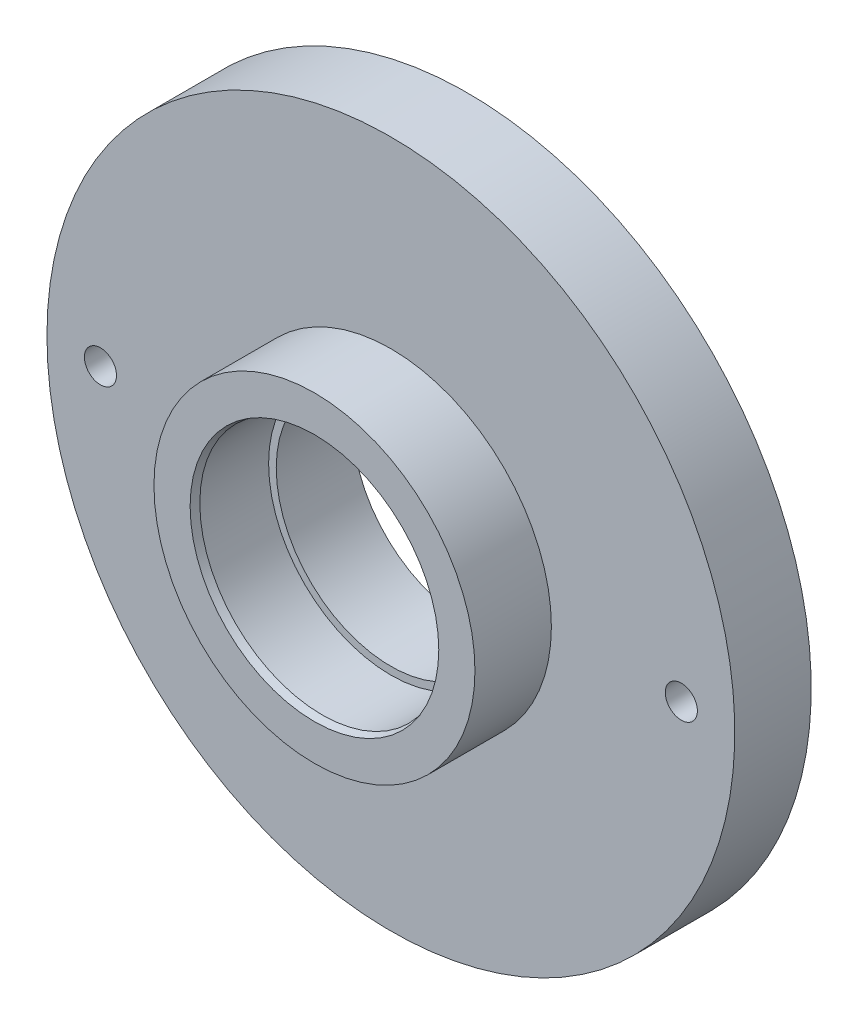
from build123d import *

# Parameters (mm, degrees)
CHAMFER1_SIZE     = 1
CHAMFER1_SIZE2    = 0.267949192
M5_TAPPED_HOLE1_D = 4.2


with BuildPart() as part:
    # Sketch1 → Revolve1 (revolve)
    with BuildSketch(Plane(origin=(0, 0, 0), x_dir=(1, 0, 0), z_dir=(0, 1, 0))):
        Polygon((16, 0), (16, 10), (15, 10), (15, 20), (45, 20), (45, 10), (21, 10), (21, 0), align=None)
    revolve(axis=Axis((0, 0, 0), (0, 0, 1)))

    # Chamfer1
    chamfer1_edges = [part.edges().sort_by_distance(p)[0] for p in [
        (-16, 0, 0),
    ]]
    chamfer1_side = [part.faces().sort_by_distance(p)[0] for p in [
        (-16, 0, -5),
    ]]
    chamfer(chamfer1_edges, length=CHAMFER1_SIZE, length2=CHAMFER1_SIZE2, reference=chamfer1_side[0])

    # M5 Tapped Hole1 (through all)
    with Locations(Plane.XY.offset(-10)):
        with Locations((-38, 0), (38, 0)):
            Hole(M5_TAPPED_HOLE1_D / 2)


solid = part.part
